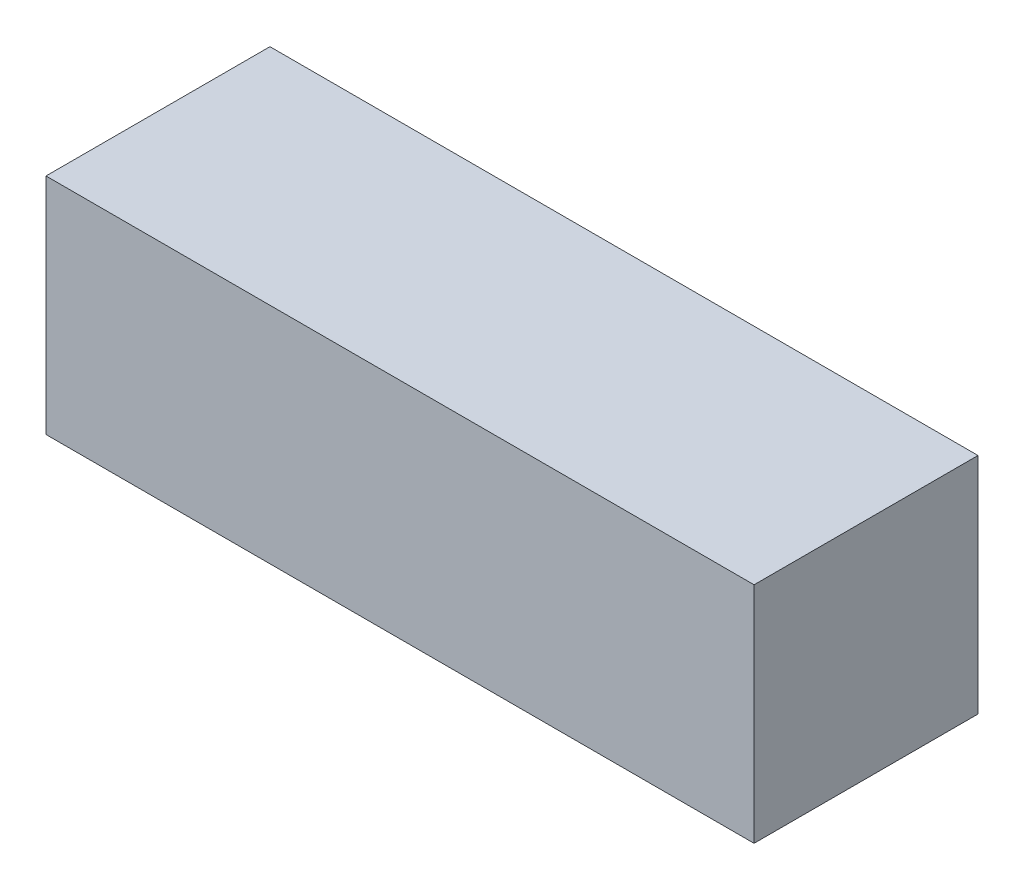
from build123d import *

# Parameters (mm, degrees)
SCHIZZO1_W                   = 160
SCHIZZO1_H                   = 50.6
ESTRUSIONE_ESTRUSIONE1_DEPTH = 50.6


with BuildPart() as part:
    # Schizzo1 → Estrusione-Estrusione1 (new body)
    with BuildSketch(Plane(origin=(0, 0, 0), x_dir=(1, 0, 0), z_dir=(0, 1, 0))):
        Rectangle(SCHIZZO1_W, SCHIZZO1_H)
    extrude(amount=ESTRUSIONE_ESTRUSIONE1_DEPTH)


solid = part.part
